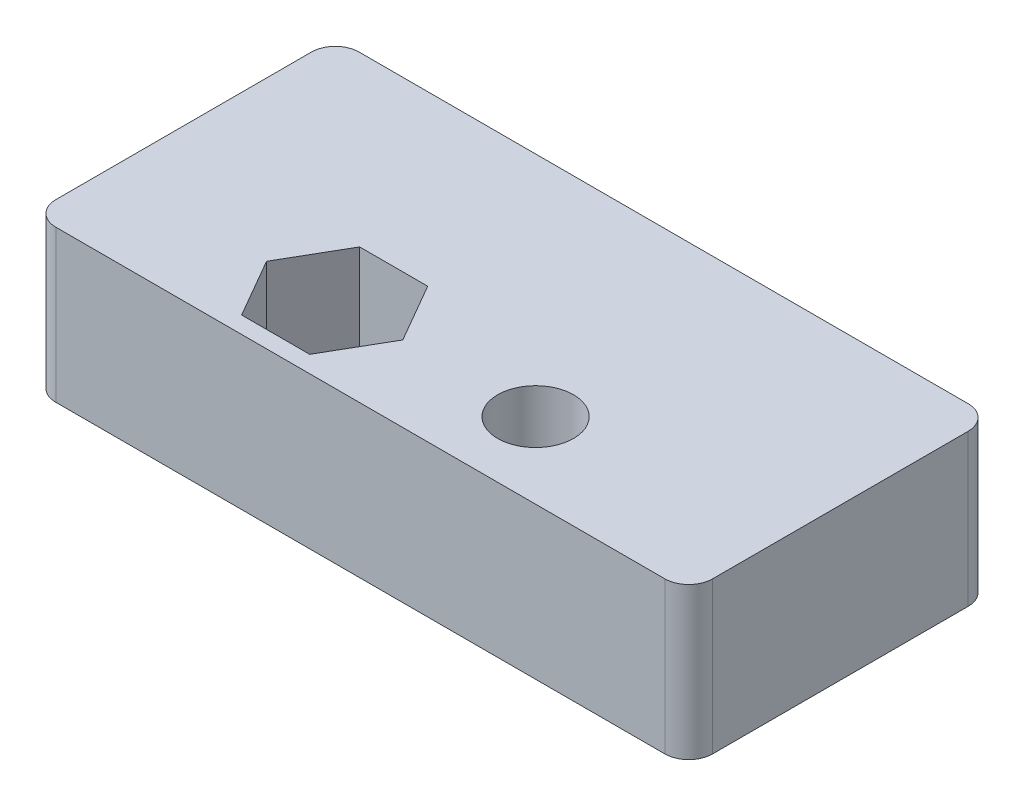
from build123d import *

# Parameters (mm, degrees)
SKETCH1_W           = 27.5
SKETCH1_H           = 12.7
SKETCH1_R           = 1.5875
BOSS_EXTRUDE1_DEPTH = 6.35
FILLET1_R           = 1


with BuildPart() as part:
    # Sketch1 → Boss-Extrude1 (new body)
    with BuildSketch(Plane(origin=(0, 0, 0), x_dir=(1, 0, 0), z_dir=(0, 1, 0))):
        with Locations((13.75, 6.35)):
            Rectangle(SKETCH1_W, SKETCH1_H)
        with Locations((17.9125, 3.175)):
            Circle(SKETCH1_R, mode=Mode.SUBTRACT)
        Polygon((12.352283535, 3.175), (10.926141767, 5.64515), (8.073858233, 5.64515), (6.647716465, 3.175), (8.073858233, 0.70485), (10.926141767, 0.70485), align=None, mode=Mode.SUBTRACT)
    extrude(amount=BOSS_EXTRUDE1_DEPTH)

    # Fillet1
    fillet1_edges = [part.edges().sort_by_distance(p)[0] for p in [
        (0, 3.175, -12.7),
        (27.5, 3.175, -12.7),
        (27.5, 3.175, 0),
        (0, 3.175, 0),
    ]]
    fillet(fillet1_edges, radius=FILLET1_R)


solid = part.part
